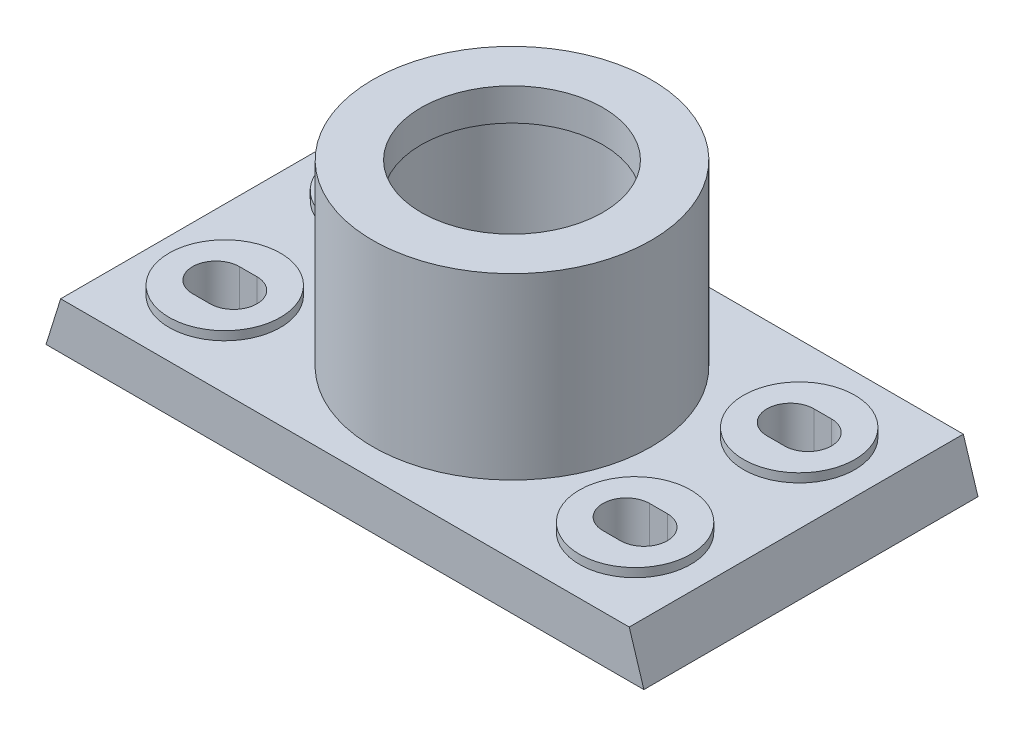
from build123d import *

# Parameters (mm, degrees)
BOSS_EXTRUDE1_DEPTH       = 114
SKETCH2_R                 = 31
CUT_EXTRUDE1_DEPTH        = 61
CUT_EXTRUDE2_DEPTH        = 61
SKETCH5_R                 = 32.5
CUT_EXTRUDE3_DEPTH        = 37
CUT_EXTRUDE4_DEPTH        = 17
SKETCH7_R                 = 19
BOSS_EXTRUDE3_DEPTH       = 3
SKETCH8_W                 = 85.5
SKETCH8_H                 = 10
BOSS_EXTRUDE4_DEPTH       = 3
SKETCH9_W                 = 85.5
SKETCH9_H                 = 10
BOSS_EXTRUDE5_DEPTH       = 3
F_3_0MM_DOWEL_HOLE1_D     = 3
F_3_0MM_DOWEL_HOLE1_DEPTH = 5


with BuildPart() as part:
    # Sketch1 → Boss-Extrude1 (new body)
    with BuildSketch(Plane.XY):
        Polygon((-6.5, 3), (-6.5, 0), (0, 0), (0, 77), (-47.5, 77), (-47.5, 16), (-97, 16), (-102, 0), (-92, 0), (-92, 3), align=None)
        Polygon((0, 77), (0, 0), (6.5, 0), (6.5, 3), (92, 3), (92, 0), (102, 0), (97, 16), (47.5, 16), (47.5, 77), align=None)
    extrude(amount=BOSS_EXTRUDE1_DEPTH)

    # Sketch2 → Cut-Extrude1 (cut)
    with BuildSketch(Plane(origin=(0, 77, 0), x_dir=(1, 0, 0), z_dir=(0, 1, 0))):
        with Locations(Location((0, -57, 0), (0, 0, 180))):  # turned: the seam where the file's is
            Circle(SKETCH2_R)
    extrude(amount=-CUT_EXTRUDE1_DEPTH, mode=Mode.SUBTRACT)

    # Sketch3 → Cut-Extrude2 (cut)
    with BuildSketch(Plane(origin=(0, 77, 0), x_dir=(1, 0, 0), z_dir=(0, 1, 0))):
        with BuildLine():
            Line((-47.5, 0), (-47.5, -57))
            ThreePointArc((-47.5, -57), (0, -9.5), (47.5, -57))
            Line((47.5, -57), (47.5, 0))
            Line((47.5, 0), (-47.5, 0))
        make_face()
        with BuildLine():
            ThreePointArc((47.5, -57), (0, -104.5), (-47.5, -57))
            Line((-47.5, -57), (-47.5, -114))
            Line((-47.5, -114), (47.5, -114))
            Line((47.5, -114), (47.5, -57))
        make_face()
    extrude(amount=-CUT_EXTRUDE2_DEPTH, mode=Mode.SUBTRACT)

    # Sketch5 → Cut-Extrude3 (cut)
    with BuildSketch(Plane(origin=(0, 66, 0), x_dir=(1, 0, 0), z_dir=(0, 1, 0))):
        with Locations(Location((0, -57, 0), (0, 0, 180))):  # turned: the seam where the file's is
            Circle(SKETCH5_R)
    extrude(amount=-CUT_EXTRUDE3_DEPTH, mode=Mode.SUBTRACT)

    # Sketch6 → Cut-Extrude4 (cut, through all)
    with BuildSketch(Plane(origin=(0, 16, 0), x_dir=(1, 0, 0), z_dir=(0, 1, 0))):
        with BuildLine():
            Line((-73, -21), (-67, -21))
            ThreePointArc((-67, -21), (-59, -29), (-67, -37))
            Line((-67, -37), (-73, -37))
            ThreePointArc((-73, -37), (-81, -29), (-73, -21))
        make_face()
        with BuildLine():
            Line((67, -21), (73, -21))
            ThreePointArc((73, -21), (81, -29), (73, -37))
            Line((73, -37), (67, -37))
            ThreePointArc((67, -37), (59, -29), (67, -21))
        make_face()
        with BuildLine():
            Line((67, -77), (73, -77))
            ThreePointArc((73, -77), (81, -85), (73, -93))
            Line((73, -93), (67, -93))
            ThreePointArc((67, -93), (59, -85), (67, -77))
        make_face()
        with BuildLine():
            Line((-73, -77), (-67, -77))
            ThreePointArc((-67, -77), (-59, -85), (-67, -93))
            Line((-67, -93), (-73, -93))
            ThreePointArc((-73, -93), (-81, -85), (-73, -77))
        make_face()
    extrude(amount=-CUT_EXTRUDE4_DEPTH, mode=Mode.SUBTRACT)

    # Sketch7 → Boss-Extrude3 (add)
    with BuildSketch(Plane(origin=(0, 16, 0), x_dir=(1, 0, 0), z_dir=(0, 1, 0))):
        with Locations(Location((-70, -29, 0), (0, 0, 180))):  # turned: the seam where the file's is
            Circle(SKETCH7_R)
        with BuildLine():
            Line((-67, -37), (-73, -37))
            ThreePointArc((-73, -37), (-81, -29), (-73, -21))
            Line((-73, -21), (-67, -21))
            ThreePointArc((-67, -21), (-59, -29), (-67, -37))
        make_face(mode=Mode.SUBTRACT)
        with Locations(Location((70, -29, 0), (0, 0, 180))):  # turned: the seam where the file's is
            Circle(SKETCH7_R)
        with BuildLine():
            Line((73, -37), (67, -37))
            ThreePointArc((67, -37), (59, -29), (67, -21))
            Line((67, -21), (73, -21))
            ThreePointArc((73, -21), (81, -29), (73, -37))
        make_face(mode=Mode.SUBTRACT)
        with Locations(Location((70, -85, 0), (0, 0, 180))):  # turned: the seam where the file's is
            Circle(SKETCH7_R)
        with BuildLine():
            Line((73, -93), (67, -93))
            ThreePointArc((67, -93), (59, -85), (67, -77))
            Line((67, -77), (73, -77))
            ThreePointArc((73, -77), (81, -85), (73, -93))
        make_face(mode=Mode.SUBTRACT)
        with Locations(Location((-70, -85, 0), (0, 0, 180))):  # turned: the seam where the file's is
            Circle(SKETCH7_R)
        with BuildLine():
            Line((-67, -93), (-73, -93))
            ThreePointArc((-73, -93), (-81, -85), (-73, -77))
            Line((-73, -77), (-67, -77))
            ThreePointArc((-67, -77), (-59, -85), (-67, -93))
        make_face(mode=Mode.SUBTRACT)
    extrude(amount=BOSS_EXTRUDE3_DEPTH)

    # Sketch8 → Boss-Extrude4 (add)
    with BuildSketch(Plane(origin=(0, 3, 0), x_dir=(-1, 0, 0), z_dir=(0, -1, 0))):
        with Locations((49.25, -5)):
            Rectangle(SKETCH8_W, SKETCH8_H)
        with Locations((49.25, -109)):
            Rectangle(SKETCH8_W, SKETCH8_H)
    extrude(amount=BOSS_EXTRUDE4_DEPTH)

    # Sketch9 → Boss-Extrude5 (add)
    with BuildSketch(Plane(origin=(0, 3, 0), x_dir=(-1, 0, 0), z_dir=(0, -1, 0))):
        with Locations((-49.25, -109)):
            Rectangle(SKETCH9_W, SKETCH9_H)
        with Locations((-49.25, -5)):
            Rectangle(SKETCH9_W, SKETCH9_H)
    extrude(amount=BOSS_EXTRUDE5_DEPTH)

    # Ø3.0mm Dowel Hole1
    with Locations(Plane(origin=(0, 16, 0), x_dir=(1, 0, 0), z_dir=(0, 1, 0))):
        with Locations((-22, -57)):
            Hole(F_3_0MM_DOWEL_HOLE1_D / 2, depth=F_3_0MM_DOWEL_HOLE1_DEPTH)


solid = part.part
